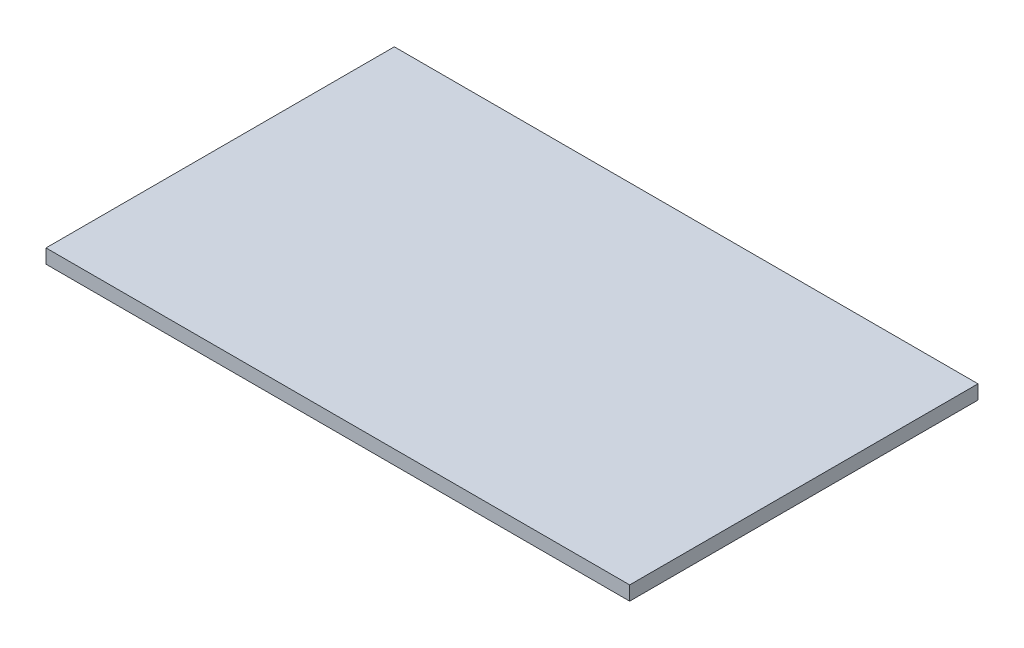
from build123d import *

# Parameters (mm, degrees)
SKETCH1_W           = 62
SKETCH1_H           = 37
BOSS_EXTRUDE1_DEPTH = 1.5


with BuildPart() as part:
    # Sketch1 → Boss-Extrude1 (new body)
    with BuildSketch(Plane(origin=(0, 0, 0), x_dir=(1, 0, 0), z_dir=(0, 1, 0))):
        with Locations((31, 18.5)):
            Rectangle(SKETCH1_W, SKETCH1_H)
    extrude(amount=BOSS_EXTRUDE1_DEPTH)


solid = part.part
